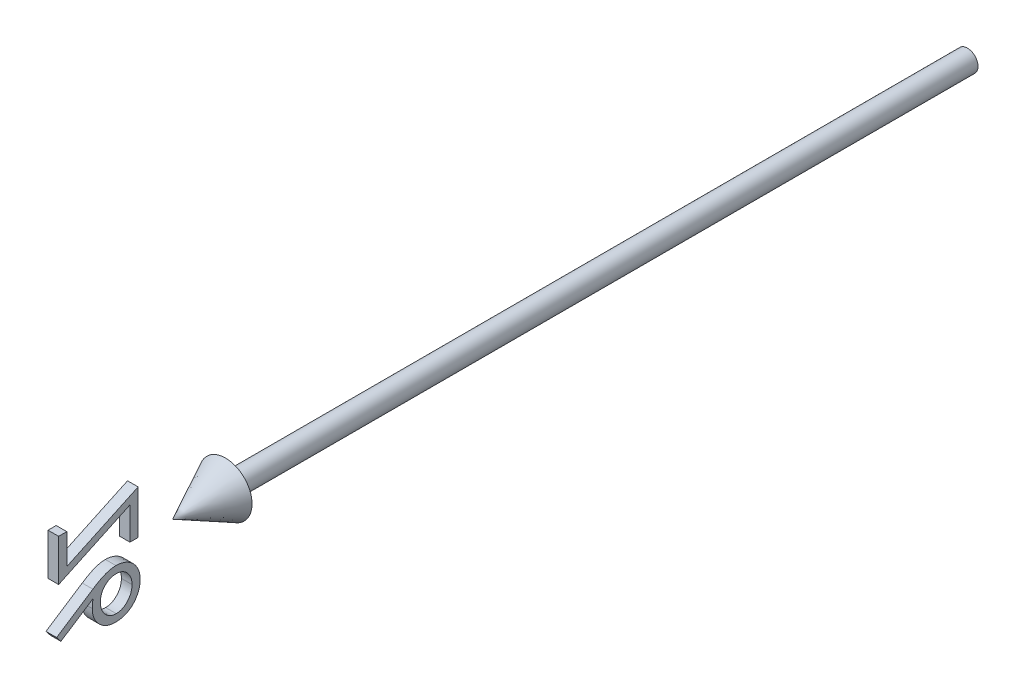
from build123d import *

# Parameters (mm, degrees)
BOSS_EXTRUDE1_DEPTH        = 1
BOSS_EXTRUDE1_DEPTH_BACK   = 1
BOSS_EXTRUDE1_2_DEPTH      = 1
BOSS_EXTRUDE1_2_DEPTH_BACK = 1


with BuildPart() as part:
    # Sketch2 → Revolve1 (revolve)
    with BuildSketch(Plane(origin=(0, 0, 0), x_dir=(1, 0, 0), z_dir=(0, 1, 0))):
        Polygon((0, -150), (5, -140), (2, -140), (2, 0), (0, 0), align=None)
    revolve(axis=Axis((0, 0, -41.949952025), (0, 0, 1)))


with BuildPart() as body_2:
    # Sketch3 → Boss-Extrude1 (new, two sides: drawn at the far end of the back side and taken through both)
    with BuildSketch(Plane(origin=(0, 0, 0), x_dir=(0, -1, 0), z_dir=(1, 0, 0)).offset(-BOSS_EXTRUDE1_DEPTH_BACK)):
        Polygon((-8.958586521, -170.961538462), (-8.958586521, -172.5), (-1.073971137, -172.5), (-7.366038444, -159.038461538), (-1.266278829, -159.038461538), (-1.266278829, -157.5), (-9.535509598, -157.5), (-3.243442291, -170.961538462), align=None)
    extrude(amount=BOSS_EXTRUDE1_DEPTH + BOSS_EXTRUDE1_DEPTH_BACK)


with BuildPart() as body_3:
    # Sketch3 → Boss-Extrude1 2 (new, two sides: drawn at the far end of the back side and taken through both)
    with BuildSketch(Plane(origin=(0, 0, 0), x_dir=(0, -1, 0), z_dir=(1, 0, 0)).offset(-BOSS_EXTRUDE1_2_DEPTH_BACK)):
        with BuildLine():
            Line((7.387567325, -172.884615385), (8.424225979, -172.0703125))
            Line((8.424225979, -172.0703125), (4.460884633, -166.009615385))
            add(Edge.make_bspline(
                [(4.460884633, -166.009615385), (4.724757248, -166.051674787), (5.23947062, -166.133716408), (5.760467328, -166.14725046), (6.014370209, -166.153846154)],
                knots=[0, 0, 0, 0, 1.025318673, 2, 2, 2, 2], degree=3))
            add(Edge.make_bspline(
                [(6.014370209, -166.153846154), (6.166823765, -166.149748532), (6.466924054, -166.141682487), (6.90752463, -166.079608839), (7.330905801, -165.981786938), (7.73531265, -165.839191529), (8.122197082, -165.657038681), (8.493777932, -165.43872886), (8.843075506, -165.17299167), (9.174568059, -164.876136314), (9.475587859, -164.547369878), (9.741888404, -164.198432357), (9.96680146, -163.829351346), (10.14599094, -163.440209844), (10.289195068, -163.034053996), (10.391138976, -162.609299766), (10.452082579, -162.165230263), (10.460310746, -161.863171943), (10.464490402, -161.709735577)],
                knots=[0, 0, 0, 0, 1.043709831, 2.054511743, 3.041122595, 4.01515914, 4.98481438, 5.965901842, 6.960491961, 7.985277438, 9.0096037, 10.00832444, 10.987059228, 11.962929573, 12.936966118, 13.931840027, 14.949438142, 16, 16, 16, 16], degree=3))
            add(Edge.make_bspline(
                [(10.464490402, -161.709735577), (10.45667713, -161.499939569), (10.441311524, -161.08735409), (10.329035926, -160.484047587), (10.136701892, -159.914243011), (9.875246254, -159.376452548), (9.542487381, -158.881938665), (9.143368233, -158.436516889), (8.679859323, -158.048269515), (8.161189367, -157.715354194), (7.599903237, -157.450815338), (7.011356352, -157.255246112), (6.40060363, -157.138386318), (5.985817631, -157.123087117), (5.776990402, -157.115384615)],
                knots=[0, 0, 0, 0, 1.0319111, 2.029359566, 3.00642934, 3.98275322, 4.962714161, 5.929339302, 6.915525103, 7.928435063, 8.953439721, 9.960121214, 10.9730072, 12, 12, 12, 12], degree=3))
            add(Edge.make_bspline(
                [(5.776990402, -157.115384615), (5.575138865, -157.12191544), (5.175306311, -157.13485186), (4.587290587, -157.250692626), (4.021275897, -157.437113987), (3.484540848, -157.699332813), (2.986473856, -158.024936501), (2.537456198, -158.414250968), (2.148849642, -158.867528729), (1.824265766, -159.376311485), (1.558647205, -159.918720222), (1.3730556, -160.490451538), (1.252389216, -161.079656481), (1.239971685, -161.480781294), (1.233721171, -161.682692308)],
                knots=[0, 0, 0, 0, 1.01206923, 2.004731945, 2.994948482, 3.995280086, 4.993424783, 5.973125358, 6.967517142, 7.97830003, 8.994392566, 9.989381197, 10.98793077, 12, 12, 12, 12], degree=3))
            add(Edge.make_bspline(
                [(1.233721171, -161.682692308), (1.239157378, -161.837112847), (1.250252135, -162.152269778), (1.316464364, -162.630964519), (1.437905683, -163.118852651), (1.569331733, -163.532448307), (1.699746048, -163.874980445), (1.820669201, -164.145469026), (1.95587602, -164.431113653), (2.114357241, -164.726509648), (2.282360125, -165.040097115), (2.478606559, -165.360262952), (2.683392728, -165.698700605), (2.833413854, -165.924027137), (2.910403863, -166.039663462)],
                knots=[0, 0, 0, 0, 1.17367173, 2.395347028, 3.66355231, 4.98980831, 5.690886799, 6.447442954, 7.240630024, 8.091733897, 8.994365608, 9.943299771, 10.944512865, 12, 12, 12, 12], degree=3))
            Line((2.910403863, -166.039663462), (7.387567325, -172.884615385))
        make_face()
        with BuildLine():
            add(Edge.make_bspline(
                [(5.731918286, -164.615384615), (5.617643803, -164.612038432), (5.393438208, -164.605473249), (5.065103103, -164.567575452), (4.754169296, -164.498211914), (4.461147017, -164.400575861), (4.181711815, -164.281289821), (3.920302291, -164.13002039), (3.675159154, -163.952130825), (3.451943564, -163.747382358), (3.246922766, -163.526633888), (3.070584936, -163.288737062), (2.918306509, -163.041006028), (2.794537717, -162.781100358), (2.698148876, -162.509189913), (2.628428562, -162.226506566), (2.589626566, -161.931159769), (2.583171317, -161.730877583), (2.579875017, -161.628605769)],
                knots=[0, 0, 0, 0, 1.129540697, 2.216149546, 3.260829642, 4.271906843, 5.264942922, 6.258225651, 7.250175744, 8.252297429, 9.247108021, 10.223125336, 11.173816288, 12.116901384, 13.062424938, 14.020354563, 14.989116641, 16, 16, 16, 16], degree=3))
            add(Edge.make_bspline(
                [(2.579875017, -161.628605769), (2.582661394, -161.527270268), (2.588152291, -161.327576232), (2.634686617, -161.034379419), (2.709592422, -160.753131579), (2.816076551, -160.483239431), (2.952112837, -160.225113333), (3.114819392, -159.975632853), (3.312115114, -159.741438867), (3.5362472, -159.521085993), (3.779792579, -159.319445103), (4.036823461, -159.139166208), (4.308262109, -158.989531157), (4.591217774, -158.864457508), (4.889245249, -158.772569713), (5.197297603, -158.702173196), (5.519619865, -158.663697577), (5.737835651, -158.657173061), (5.849105786, -158.653846154)],
                knots=[0, 0, 0, 0, 0.98953633, 1.950002717, 2.892353065, 3.828177645, 4.777967117, 5.738732544, 6.732276577, 7.76327951, 8.805689376, 9.818183401, 10.825652611, 11.829169732, 12.834974292, 13.867693979, 14.912718532, 16, 16, 16, 16], degree=3))
            add(Edge.make_bspline(
                [(5.849105786, -158.653846154), (5.960376104, -158.657172802), (6.178592248, -158.66369681), (6.500911916, -158.702176111), (6.808973852, -158.772559029), (7.106966521, -158.864496219), (7.390051273, -158.989386675), (7.661727396, -159.140109433), (7.92121244, -159.318352216), (8.164599428, -159.521434681), (8.389666859, -159.740188862), (8.582429019, -159.97777361), (8.750382815, -160.223149948), (8.88123106, -160.484266134), (8.988907437, -160.752971083), (9.063446275, -161.034423223), (9.110079809, -161.327564804), (9.115557089, -161.527266421), (9.118336556, -161.628605769)],
                knots=[0, 0, 0, 0, 1.087095469, 2.131941252, 3.164484274, 4.170116773, 5.173462224, 6.180759088, 7.201132453, 8.243363996, 9.274190558, 10.261329848, 11.227346438, 12.172477233, 13.108141724, 14.050330866, 15.010632948, 16, 16, 16, 16], degree=3))
            add(Edge.make_bspline(
                [(9.118336556, -161.628605769), (9.116005645, -161.731022874), (9.111430827, -161.932034344), (9.058685072, -162.22624047), (8.987443172, -162.511488594), (8.872309656, -162.781352824), (8.735176504, -163.043296813), (8.560476842, -163.289830887), (8.360183356, -163.527951683), (8.1282086, -163.748845574), (7.8758991, -163.951035701), (7.607372218, -164.128979892), (7.327575224, -164.280878587), (7.032553285, -164.400737488), (6.726279448, -164.497297507), (6.406637889, -164.567110851), (6.073401532, -164.605532255), (5.847195868, -164.612058665), (5.731918286, -164.615384615)],
                knots=[0, 0, 0, 0, 0.978317929, 1.920119929, 2.851929572, 3.784133089, 4.71845084, 5.67514162, 6.667477147, 7.690549442, 8.733345855, 9.756283585, 10.767808623, 11.772962645, 12.797066014, 13.836159554, 14.89727653, 16, 16, 16, 16], degree=3))
        make_face(mode=Mode.SUBTRACT)
    extrude(amount=BOSS_EXTRUDE1_2_DEPTH + BOSS_EXTRUDE1_2_DEPTH_BACK)


solid = Compound([part.part, body_2.part, body_3.part])
